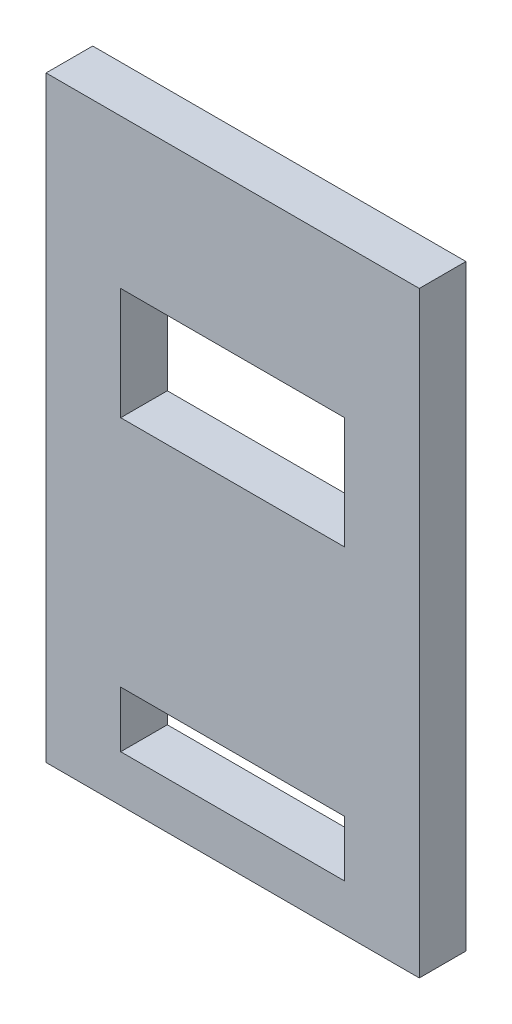
from build123d import *

# Parameters (mm, degrees)
SKETCH1_W           = 127
SKETCH1_H           = 203.2
BOSS_EXTRUDE1_DEPTH = 15.875
SKETCH2_W           = 76.2
SKETCH2_H           = 38.1
SKETCH2_H_2         = 19.05
CUT_EXTRUDE2_DEPTH  = 16.875


with BuildPart() as part:
    # Sketch1 → Boss-Extrude1 (new body)
    with BuildSketch(Plane.XY):
        with Locations((20.711469534, 4.415412186)):
            Rectangle(SKETCH1_W, SKETCH1_H)
    extrude(amount=BOSS_EXTRUDE1_DEPTH)

    # Sketch2 → Cut-Extrude2 (cut, through all)
    with BuildSketch(Plane.XY.offset(15.875)):
        with Locations((20.711469534, 36.165412186)):
            Rectangle(SKETCH2_W, SKETCH2_H)
        with Locations((20.711469534, -71.784587814)):
            Rectangle(SKETCH2_W, SKETCH2_H_2)
    extrude(amount=-CUT_EXTRUDE2_DEPTH, mode=Mode.SUBTRACT)


solid = part.part
